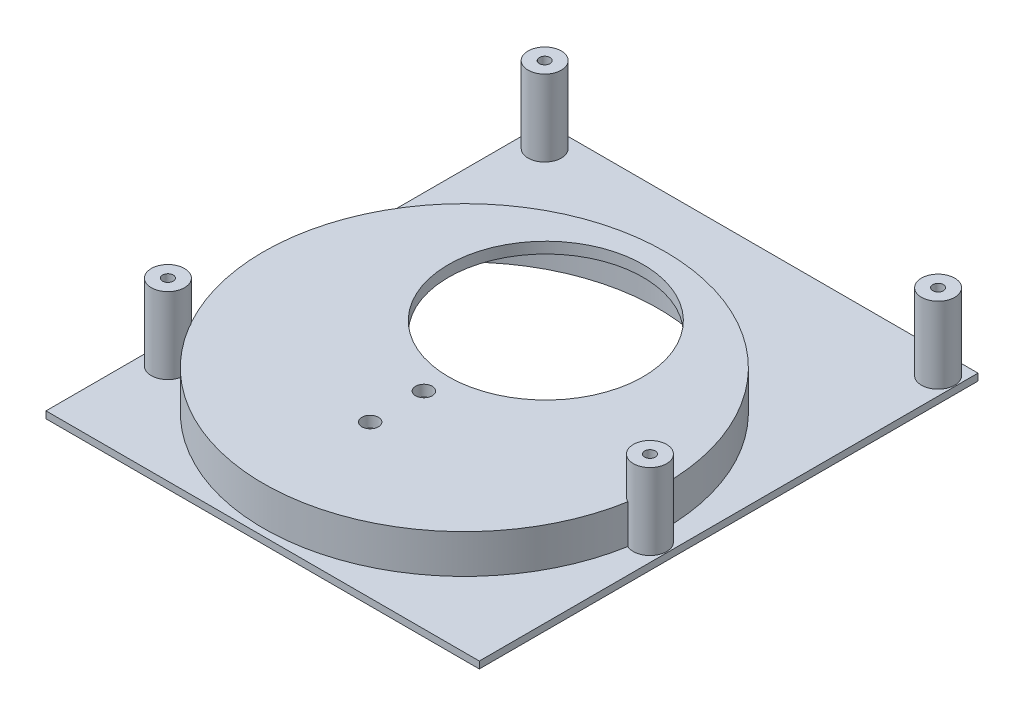
from build123d import *

# Parameters (mm, degrees)
SKETCH1_W                        = 99.314
SKETCH1_H                        = 114.3
MAIN_DEPTH                       = 1.5875
SKETCH3_R                        = 46.0375
RAISED_DISK_EDGE_DEPTH           = 10.4775
SKETCH4_R                        = 44.45
DISK_HOLLOW_DEPTH                = 8.9375
SKETCH5_R                        = 1.905
SCREW_HOLES_ON_FRONT_PANEL_DEPTH = 2.54
SKETCH6_R                        = 3.81
SKETCH6_R_2                      = 1.2239625
MOUNTING_POSTS_DEPTH             = 17.4625
HOLLOW_REACH                     = 12.478
SKETCH8_R                        = 22.29794733


with BuildPart() as part:
    # Sketch1 → main (new body)
    with BuildSketch(Plane(origin=(0, 0, 0), x_dir=(1, 0, 0), z_dir=(0, 1, 0))):
        with Locations((-31.731304389, 36.593342839)):
            Rectangle(SKETCH1_W, SKETCH1_H)
    extrude(amount=MAIN_DEPTH)


with BuildPart() as body_2:
    # Sketch3 → raised disk edge (new body)
    with BuildSketch(Plane(origin=(0, 0, 0), x_dir=(1, 0, 0), z_dir=(0, 1, 0))):
        with Locations((-33.128304389, 27.068342839)):
            Circle(SKETCH3_R)
    extrude(amount=RAISED_DISK_EDGE_DEPTH)


with BuildPart() as disk_hollow_tool:
    # Sketch4 → disk hollow (new body, through all)
    with BuildSketch(Plane(origin=(0, 7.9375, 0), x_dir=(1, 0, 0), z_dir=(0, 1, 0))):
        with Locations((-33.128304389, 27.068342839)):
            Circle(SKETCH4_R)
    extrude(amount=-DISK_HOLLOW_DEPTH)


with BuildPart() as part_1:
    add(part.part)

    # disk hollow: cut by disk_hollow_tool
    add(disk_hollow_tool.part, mode=Mode.SUBTRACT)



with BuildPart() as body_2_1:
    add(body_2.part)

    # disk hollow: cut by disk_hollow_tool
    add(disk_hollow_tool.part, mode=Mode.SUBTRACT)

    # Sketch5 → screw holes on front panel (cut)
    with BuildSketch(Plane(origin=(0, 10.4775, 0), x_dir=(1, 0, 0), z_dir=(0, 1, 0))):
        with Locations((-33.128304389, 17.797342839)):
            Circle(SKETCH5_R)
        with Locations((-33.128304389, 5.478342839)):
            Circle(SKETCH5_R)
    extrude(amount=-SCREW_HOLES_ON_FRONT_PANEL_DEPTH, mode=Mode.SUBTRACT)


with BuildPart() as part_2:
    add(part_1.part)

    add(body_2_1.part)  # mounting posts merges body 2
    # Sketch6 → mounting posts (add)
    with BuildSketch(Plane(origin=(0, 1.5875, 0), x_dir=(1, 0, 0), z_dir=(0, 1, 0))):
        with Locations((-76.308304389, 2.303342839)):
            Circle(SKETCH6_R)
        with Locations((-76.308304389, 2.303342839)):
            Circle(SKETCH6_R_2, mode=Mode.SUBTRACT)
        with Locations((13.861695611, 22.623342839)):
            Circle(SKETCH6_R)
        with Locations((13.861695611, 22.623342839)):
            Circle(SKETCH6_R_2, mode=Mode.SUBTRACT)
        with Locations((-76.308304389, 88.663342839)):
            Circle(SKETCH6_R)
        with Locations((-76.308304389, 88.663342839)):
            Circle(SKETCH6_R_2, mode=Mode.SUBTRACT)
        with Locations((13.861695611, 88.663342839)):
            Circle(SKETCH6_R)
        with Locations((13.861695611, 88.663342839)):
            Circle(SKETCH6_R_2, mode=Mode.SUBTRACT)
    extrude(amount=MOUNTING_POSTS_DEPTH)

    # Sketch8 → hollow (cut, up to next)
    with BuildSketch(Plane(origin=(0, 10.4775, 0), x_dir=(1, 0, 0), z_dir=(0, 1, 0)), mode=Mode.PRIVATE) as hollow_sk1:
        with Locations((-33.128304389, 45.737342839)):
            Circle(SKETCH8_R)
    hollow_tool1 = extrude(hollow_sk1.sketch, amount=-HOLLOW_REACH, mode=Mode.PRIVATE) & part_2.part
    add(hollow_tool1.solids().sort_by_distance((-33.128304, 10.4775, -45.737343))[0], mode=Mode.SUBTRACT)


solid = part_2.part
